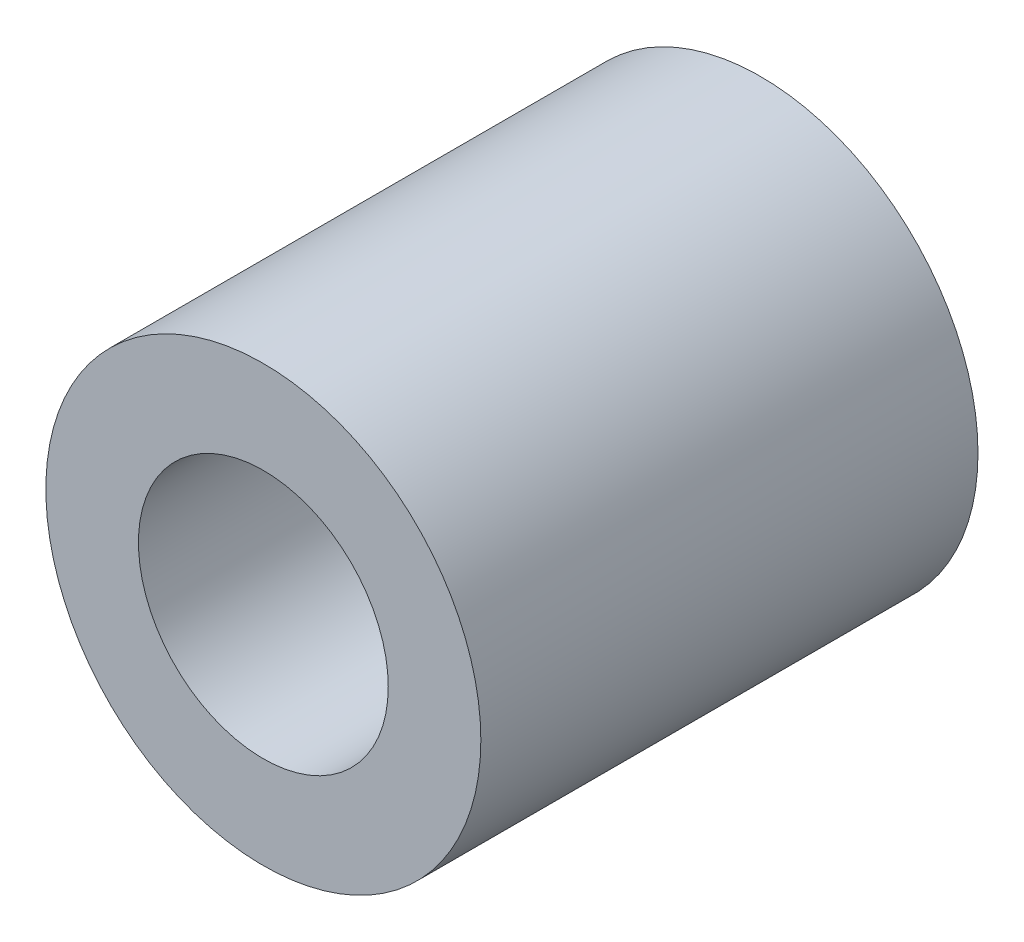
from build123d import *

# Parameters (mm, degrees)
ESQUISSE1_R        = 17.5
ESQUISSE1_R_2      = 10.05
BOSS_EXTRU_1_DEPTH = 40


with BuildPart() as part:
    # Esquisse1 → Boss.-Extru.1 (new body)
    with BuildSketch(Plane.XY):
        Circle(ESQUISSE1_R)
        Circle(ESQUISSE1_R_2, mode=Mode.SUBTRACT)
    extrude(amount=BOSS_EXTRU_1_DEPTH)


solid = part.part
